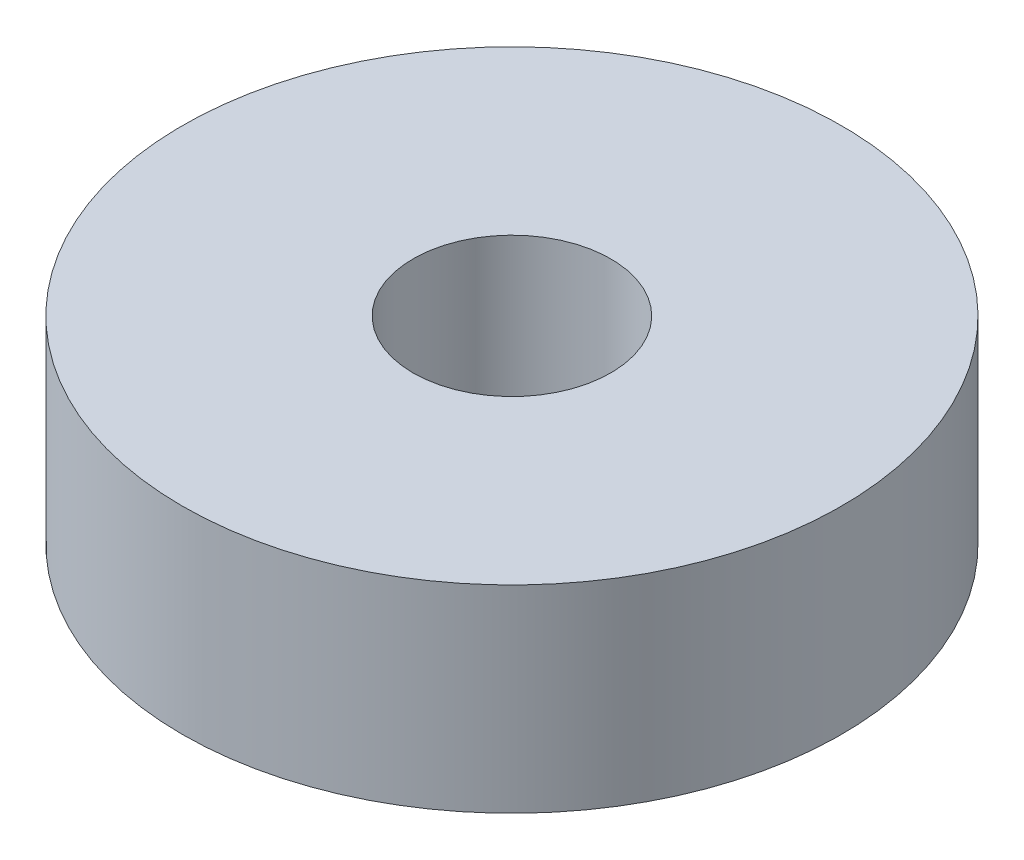
from build123d import *

# Parameters (mm, degrees)
SKETCH1_R             = 5
BOSS_EXTRUDE1_DEPTH   = 3
F_3_0MM_DOWEL_HOLE1_D = 3


with BuildPart() as part:
    # Sketch1 → Boss-Extrude1 (new body)
    with BuildSketch(Plane(origin=(0, 0, 0), x_dir=(1, 0, 0), z_dir=(0, 1, 0))):
        Circle(SKETCH1_R)
    extrude(amount=BOSS_EXTRUDE1_DEPTH)

    # Ø3.0mm Dowel Hole1 (through all)
    with Locations(Plane(origin=(0, 3, 0), x_dir=(1, 0, 0), z_dir=(0, 1, 0))):
        with Locations((0, 0)):
            Hole(F_3_0MM_DOWEL_HOLE1_D / 2)


solid = part.part
